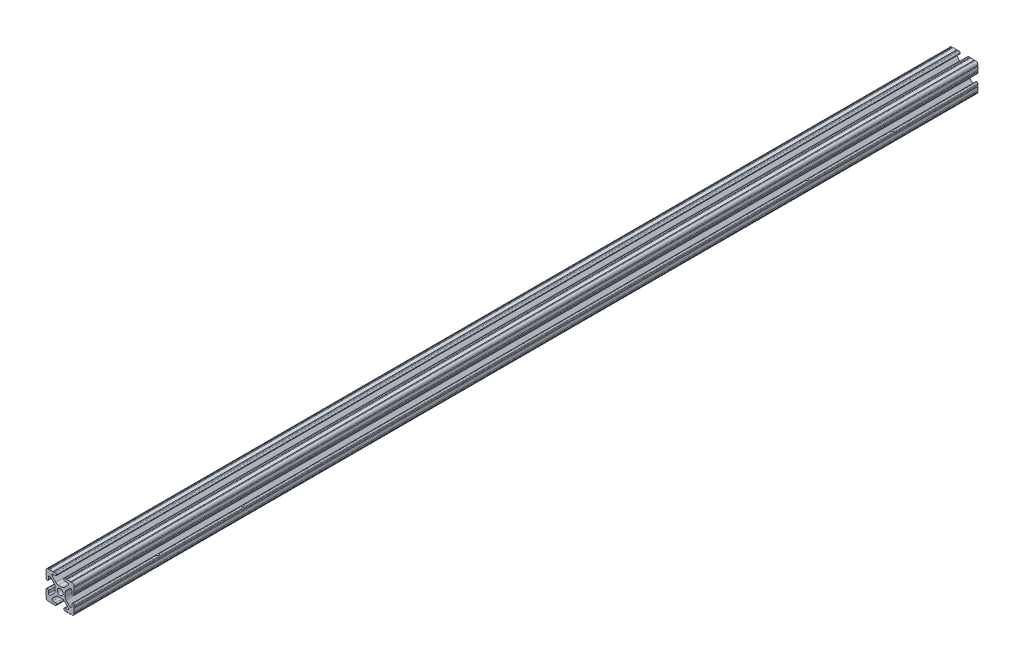
from build123d import *

# Parameters (mm, degrees)
SKETCH1_R               = 2.6035
BOSS_EXTRUDE1_DEPTH     = 406.4
SKETCH3_R               = 3.5
CUT_EXTRUDE2_DEPTH      = 9.1915
CUT_EXTRUDE2_DEPTH_BACK = 18.2085


with BuildPart() as part:
    # Sketch1 → Boss-Extrude1 (new body, symmetric)
    with BuildSketch(Plane.XY):
        with BuildLine():
            Line((-7.179650497, -8.645192506), (-3.952270251, -5.423690499))
            ThreePointArc((-3.952270251, -5.423690499), (-2.922936451, -4.736929036), (-1.709253557, -4.4958))
            Line((-1.709253557, -4.4958), (1.709253557, -4.4958))
            ThreePointArc((1.709253557, -4.4958), (2.922936451, -4.736929036), (3.952270251, -5.423690499))
            Line((3.952270251, -5.423690499), (7.179650497, -8.645192506))
            ThreePointArc((7.179650497, -8.645192506), (7.41473083, -9.822813117), (6.416408329, -10.4902))
            Line((6.416408329, -10.4902), (4.287512407, -10.4902))
            ThreePointArc((4.287512407, -10.4902), (3.54574862, -10.79744862), (3.2385, -11.539212407))
            Line((3.2385, -11.539212407), (3.2385, -11.650987593))
            ThreePointArc((3.2385, -11.650987593), (3.54574862, -12.39275138), (4.287512407, -12.7))
            Line((4.287512407, -12.7), (5.317126718, -12.7))
            ThreePointArc((5.317126718, -12.7), (5.825126718, -12.192), (6.333126718, -12.7))
            Line((6.333126718, -12.7), (9.550443118, -12.7))
            ThreePointArc((9.550443118, -12.7), (10.058366869, -12.192000006), (10.566443095, -12.699847501))
            ThreePointArc((10.566443095, -12.699847501), (12.082537762, -12.08250727), (12.699846982, -10.566399977))
            ThreePointArc((12.699846982, -10.566399977), (12.192000006, -10.058323491), (12.7, -9.5504))
            Line((12.7, -9.5504), (12.7, -6.3330836))
            ThreePointArc((12.7, -6.3330836), (12.192, -5.8250836), (12.7, -5.3170836))
            Line((12.7, -5.3170836), (12.7, -4.287469289))
            ThreePointArc((12.7, -4.287469289), (12.39275138, -3.545705502), (11.650987593, -3.238456882))
            Line((11.650987593, -3.238456882), (11.539212407, -3.238456882))
            ThreePointArc((11.539212407, -3.238456882), (10.79744862, -3.545705502), (10.4902, -4.287469289))
            Line((10.4902, -4.287469289), (10.4902, -6.402089023))
            ThreePointArc((10.4902, -6.402089023), (9.856505071, -7.351067942), (8.737131347, -7.129408934))
            Line((8.737131347, -7.129408934), (5.441005833, -3.840816462))
            ThreePointArc((5.441005833, -3.840816462), (4.750877967, -2.809883091), (4.5085, -1.593185507))
            Line((4.5085, -1.593185507), (4.5085, 1.593185507))
            ThreePointArc((4.5085, 1.593185507), (4.750877967, 2.809883091), (5.441005833, 3.840816462))
            Line((5.441005833, 3.840816462), (8.737131347, 7.129408934))
            ThreePointArc((8.737131347, 7.129408934), (9.856505071, 7.351067942), (10.4902, 6.402089023))
            Line((10.4902, 6.402089023), (10.4902, 4.287469289))
            ThreePointArc((10.4902, 4.287469289), (10.79744862, 3.545705502), (11.539212407, 3.238456882))
            Line((11.539212407, 3.238456882), (11.650987593, 3.238456882))
            ThreePointArc((11.650987593, 3.238456882), (12.39275138, 3.545705502), (12.7, 4.287469289))
            Line((12.7, 4.287469289), (12.7, 5.3170836))
            ThreePointArc((12.7, 5.3170836), (12.192, 5.8250836), (12.7, 6.3330836))
            Line((12.7, 6.3330836), (12.7, 9.5504))
            ThreePointArc((12.7, 9.5504), (12.192000006, 10.058323491), (12.699846982, 10.566399977))
            ThreePointArc((12.699846982, 10.566399977), (12.082537762, 12.08250727), (10.566443095, 12.699847501))
            ThreePointArc((10.566443095, 12.699847501), (10.058366869, 12.192000006), (9.550443118, 12.7))
            Line((9.550443118, 12.7), (6.333126718, 12.7))
            ThreePointArc((6.333126718, 12.7), (5.825126718, 12.192), (5.317126718, 12.7))
            Line((5.317126718, 12.7), (4.287512407, 12.7))
            ThreePointArc((4.287512407, 12.7), (3.54574862, 12.39275138), (3.2385, 11.650987593))
            Line((3.2385, 11.650987593), (3.2385, 11.539212407))
            ThreePointArc((3.2385, 11.539212407), (3.54574862, 10.79744862), (4.287512407, 10.4902))
            Line((4.287512407, 10.4902), (6.476788598, 10.4902))
            ThreePointArc((6.476788598, 10.4902), (7.432222385, 9.85140422), (7.207036008, 8.724370562))
            Line((7.207036008, 8.724370562), (3.898272566, 5.423169045))
            ThreePointArc((3.898272566, 5.423169045), (2.869120213, 4.736787962), (1.655778399, 4.4958))
            Line((1.655778399, 4.4958), (-1.655778399, 4.4958))
            ThreePointArc((-1.655778399, 4.4958), (-2.869120213, 4.736787962), (-3.898272566, 5.423169045))
            Line((-3.898272566, 5.423169045), (-7.207036008, 8.724370562))
            ThreePointArc((-7.207036008, 8.724370562), (-7.432222385, 9.85140422), (-6.476788598, 10.4902))
            Line((-6.476788598, 10.4902), (-4.287512407, 10.4902))
            ThreePointArc((-4.287512407, 10.4902), (-3.54574862, 10.79744862), (-3.2385, 11.539212407))
            Line((-3.2385, 11.539212407), (-3.2385, 11.650987593))
            ThreePointArc((-3.2385, 11.650987593), (-3.54574862, 12.39275138), (-4.287512407, 12.7))
            Line((-4.287512407, 12.7), (-5.317126718, 12.7))
            ThreePointArc((-5.317126718, 12.7), (-5.825126718, 12.192), (-6.333126718, 12.7))
            Line((-6.333126718, 12.7), (-9.550443118, 12.7))
            ThreePointArc((-9.550443118, 12.7), (-10.058366869, 12.192000006), (-10.566443095, 12.699847501))
            ThreePointArc((-10.566443095, 12.699847501), (-12.082537762, 12.08250727), (-12.699846982, 10.566399977))
            ThreePointArc((-12.699846982, 10.566399977), (-12.192000006, 10.058323491), (-12.7, 9.5504))
            Line((-12.7, 9.5504), (-12.7, 6.3330836))
            ThreePointArc((-12.7, 6.3330836), (-12.192, 5.8250836), (-12.7, 5.3170836))
            Line((-12.7, 5.3170836), (-12.7, 4.287469289))
            ThreePointArc((-12.7, 4.287469289), (-12.39275138, 3.545705502), (-11.650987593, 3.238456882))
            Line((-11.650987593, 3.238456882), (-11.539212407, 3.238456882))
            ThreePointArc((-11.539212407, 3.238456882), (-10.79744862, 3.545705502), (-10.4902, 4.287469289))
            Line((-10.4902, 4.287469289), (-10.4902, 6.402089023))
            ThreePointArc((-10.4902, 6.402089023), (-9.856505071, 7.351067942), (-8.737131347, 7.129408934))
            Line((-8.737131347, 7.129408934), (-5.441005833, 3.840816462))
            ThreePointArc((-5.441005833, 3.840816462), (-4.750877967, 2.809883091), (-4.5085, 1.593185507))
            Line((-4.5085, 1.593185507), (-4.5085, -1.593185507))
            ThreePointArc((-4.5085, -1.593185507), (-4.750877967, -2.809883091), (-5.441005833, -3.840816462))
            Line((-5.441005833, -3.840816462), (-8.737131347, -7.129408934))
            ThreePointArc((-8.737131347, -7.129408934), (-9.856505071, -7.351067942), (-10.4902, -6.402089023))
            Line((-10.4902, -6.402089023), (-10.4902, -4.287469289))
            ThreePointArc((-10.4902, -4.287469289), (-10.79744862, -3.545705502), (-11.539212407, -3.238456882))
            Line((-11.539212407, -3.238456882), (-11.650987593, -3.238456882))
            ThreePointArc((-11.650987593, -3.238456882), (-12.39275138, -3.545705502), (-12.7, -4.287469289))
            Line((-12.7, -4.287469289), (-12.7, -5.3170836))
            ThreePointArc((-12.7, -5.3170836), (-12.192, -5.8250836), (-12.7, -6.3330836))
            Line((-12.7, -6.3330836), (-12.7, -9.5504))
            ThreePointArc((-12.7, -9.5504), (-12.192000006, -10.058323491), (-12.699846982, -10.566399977))
            ThreePointArc((-12.699846982, -10.566399977), (-12.082537762, -12.08250727), (-10.566443095, -12.699847501))
            ThreePointArc((-10.566443095, -12.699847501), (-10.058366869, -12.192000006), (-9.550443118, -12.7))
            Line((-9.550443118, -12.7), (-6.333126718, -12.7))
            ThreePointArc((-6.333126718, -12.7), (-5.825126718, -12.192), (-5.317126718, -12.7))
            Line((-5.317126718, -12.7), (-4.287512407, -12.7))
            ThreePointArc((-4.287512407, -12.7), (-3.54574862, -12.39275138), (-3.2385, -11.650987593))
            Line((-3.2385, -11.650987593), (-3.2385, -11.539212407))
            ThreePointArc((-3.2385, -11.539212407), (-3.54574862, -10.79744862), (-4.287512407, -10.4902))
            Line((-4.287512407, -10.4902), (-6.416408329, -10.4902))
            ThreePointArc((-6.416408329, -10.4902), (-7.41473083, -9.822813117), (-7.179650497, -8.645192506))
        make_face()
        Circle(SKETCH1_R, mode=Mode.SUBTRACT)
    extrude(amount=BOSS_EXTRUDE1_DEPTH, both=True)

    # Sketch3 → Cut-Extrude2 (cut, two sides)
    with BuildSketch(Plane(origin=(4.5085, 0, 0), x_dir=(0, 0, -1), z_dir=(1, 0, 0))) as cut_extrude2_sk:
        with Locations((254, 0)):
            Circle(SKETCH3_R)
        with Locations((-254, 0)):
            Circle(SKETCH3_R)
        with Locations((330.2, 0)):
            Circle(SKETCH3_R)
        with Locations((-330.2, 0)):
            Circle(SKETCH3_R)
    extrude(amount=CUT_EXTRUDE2_DEPTH, mode=Mode.SUBTRACT)
    extrude(cut_extrude2_sk.sketch, amount=-CUT_EXTRUDE2_DEPTH_BACK, mode=Mode.SUBTRACT)


solid = part.part
